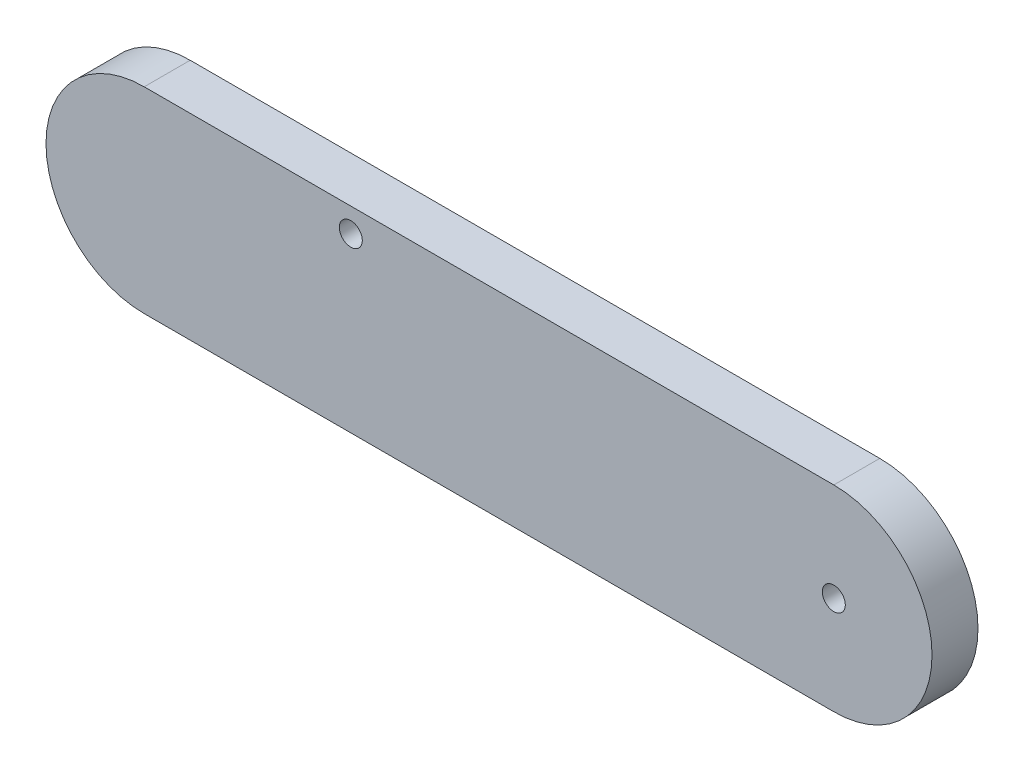
from build123d import *

# Parameters (mm, degrees)
SKETCH1_R           = 2.5
BOSS_EXTRUDE1_DEPTH = 10


with BuildPart() as part:
    # Sketch1 → Boss-Extrude1 (new body)
    with BuildSketch(Plane.XY):
        with BuildLine():
            Line((-78.338278932, 21.364985163), (71.661721068, 21.364985163))
            ThreePointArc((71.661721068, 21.364985163), (93.026706231, 0), (71.661721068, -21.364985163))
            Line((71.661721068, -21.364985163), (-78.338278932, -21.364985163))
            ThreePointArc((-78.338278932, -21.364985163), (-99.703264095, 0), (-78.338278932, 21.364985163))
        make_face()
        with Locations((71.661721068, 0)):
            Circle(SKETCH1_R, mode=Mode.SUBTRACT)
        with Locations((-33.402769588, 16.124985163)):
            Circle(SKETCH1_R, mode=Mode.SUBTRACT)
    extrude(amount=BOSS_EXTRUDE1_DEPTH)


solid = part.part
